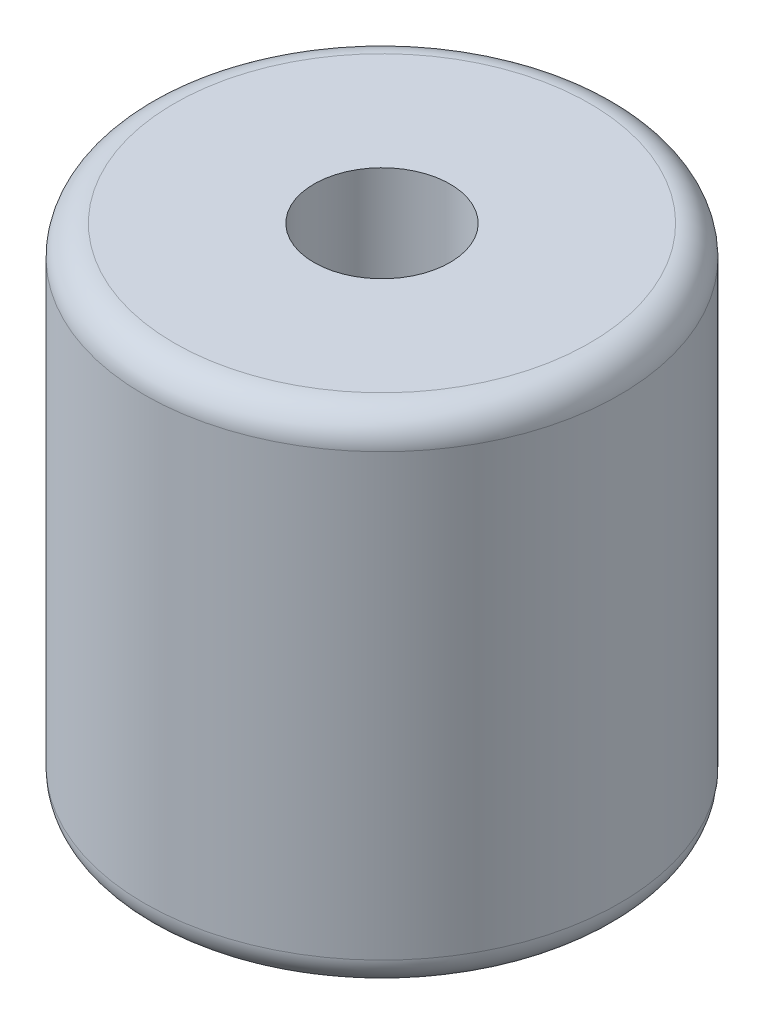
from build123d import *

# Parameters (mm, degrees)
SKETCH1_R                 = 6.0325
BOSS_EXTRUDE1_DEPTH       = 12.7
FILLET1_R                 = 0.76
F_8_32_TAPPED_HOLE1_D     = 3.4544
F_8_32_TAPPED_HOLE1_DEPTH = 11.43
F_8_32_TAPPED_HOLE1_TIP   = 1.037806461


with BuildPart() as part:
    # Sketch1 → Boss-Extrude1 (new body)
    with BuildSketch(Plane(origin=(0, 0, 0), x_dir=(1, 0, 0), z_dir=(0, 1, 0))):
        Circle(SKETCH1_R)
    extrude(amount=BOSS_EXTRUDE1_DEPTH)

    # Fillet1
    fillet1_edges = [part.edges().sort_by_distance(p)[0] for p in [
        (-6.0325, 0, 0),
        (-6.0325, 12.7, 0),
    ]]
    fillet(fillet1_edges, radius=FILLET1_R)

    # #8-32 Tapped Hole1
    with Locations(Plane(origin=(0, 12.7, 0), x_dir=(1, 0, 0), z_dir=(0, 1, 0))):
        with Locations((0, 0)):
            Hole(F_8_32_TAPPED_HOLE1_D / 2, depth=F_8_32_TAPPED_HOLE1_DEPTH)
            with Locations((0, 0, -(F_8_32_TAPPED_HOLE1_DEPTH + F_8_32_TAPPED_HOLE1_TIP / 2))):  # 118° drill point
                Cone(0, F_8_32_TAPPED_HOLE1_D / 2, F_8_32_TAPPED_HOLE1_TIP, mode=Mode.SUBTRACT)


solid = part.part
